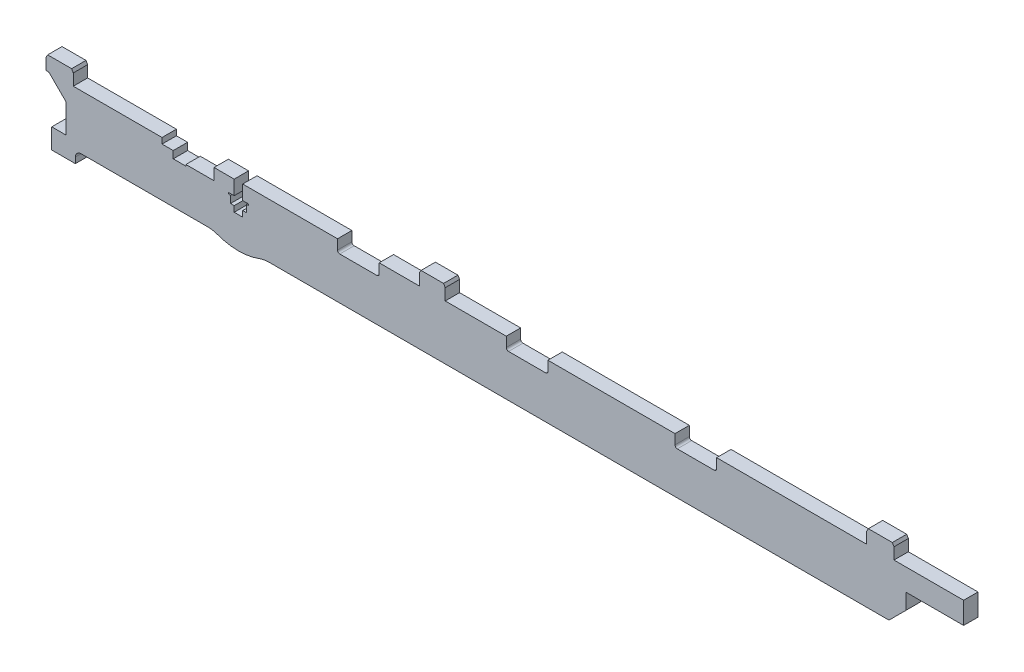
from build123d import *

# Parameters (mm, degrees)
BOSS_EXTRUDE1_DEPTH   = 5
CHAMFER1_SIZE         = 6
CUT_EXTRUDE2_DEPTH    = 6
CHAMFER3_SIZE         = 1
CHAMFER3_SIZE2        = 0.577350269
CHAMFER3_PART_2_SIZE  = 1
CHAMFER3_PART_2_SIZE2 = 0.577350269
CHAMFER3_PART_3_SIZE  = 1
CHAMFER3_PART_3_SIZE2 = 0.577350269
CHAMFER4_SIZE         = 1
CHAMFER4_SIZE2        = 0.577350269
CHAMFER4_PART_2_SIZE  = 1
CHAMFER4_PART_2_SIZE2 = 0.577350269
CHAMFER4_PART_3_SIZE  = 1
CHAMFER4_PART_3_SIZE2 = 0.577350269
FILLET1_R             = 0.8


with BuildPart() as part:
    # Sketch1 → Boss-Extrude1 (new body)
    with BuildSketch(Plane.XY):
        with BuildLine():
            Line((-250.8, 3.6), (-241, 3.6))
            Line((-241, 3.6), (-241, 7.6))
            Line((-241, 7.6), (-233.98, 7.6))
            Line((-233.98, 7.6), (-233.98, 2.6))
            Line((-233.98, 2.6), (-236, 2.6))
            Line((-236, 2.6), (-236, 2.1))
            Line((-236, 2.1), (-235.25, 2.1))
            Line((-235.25, 2.1), (-235.25, -0.4))
            Line((-235.25, -0.4), (-233.98, -0.4))
            Line((-233.98, -0.4), (-233.98, -2.4))
            Line((-233.98, -2.4), (-231.02, -2.4))
            Line((-231.02, -2.4), (-231.02, -0.4))
            Line((-231.02, -0.4), (-229.75, -0.4))
            Line((-229.75, -0.4), (-229.75, 2.1))
            Line((-229.75, 2.1), (-229, 2.1))
            Line((-229, 2.1), (-229, 2.6))
            Line((-229, 2.6), (-231.02, 2.6))
            Line((-231.02, 2.6), (-231.02, 7.6))
            Line((-231.02, 7.6), (-198, 7.6))
            Line((-198, 7.6), (-198, 3.4))
            Line((-198, 3.4), (-183.5, 3.4))
            Line((-183.5, 3.4), (-183.5, 7.6))
            Line((-183.5, 7.6), (-169.5, 7.6))
            Line((-169.5, 7.6), (-169.5, 12.6))
            Line((-169.5, 12.6), (-160.5, 12.6))
            Line((-160.5, 12.6), (-160.5, 7.6))
            Line((-160.5, 7.6), (-139.25, 7.6))
            Line((-139.25, 7.6), (-139.25, 3.4))
            Line((-139.25, 3.4), (-124.75, 3.4))
            Line((-124.75, 3.4), (-124.75, 7.6))
            Line((-124.75, 7.6), (-80.5, 7.6))
            Line((-80.5, 7.6), (-80.5, 3.4))
            Line((-80.5, 3.4), (-66, 3.4))
            Line((-66, 3.4), (-66, 7.6))
            Line((-66, 7.6), (-13.75, 7.6))
            Line((-13.75, 7.6), (-13.75, 12.6))
            Line((-13.75, 12.6), (-4.25, 12.6))
            Line((-4.25, 12.6), (-4.25, 7.6))
            Line((-4.25, 7.6), (20, 7.6))
            Line((20, 7.6), (20, 0))
            Line((20, 0), (0, 0))
            Line((0, 0), (0, -11.4))
            Line((0, -11.4), (-221.799463771, -11.4))
            ThreePointArc((-221.799463771, -11.4), (-223.557706142, -11.555784248), (-225.261167219, -12.018283247))
            ThreePointArc((-225.261167219, -12.018283247), (-232.5, -13.3111869), (-239.738832781, -12.018283247))
            ThreePointArc((-239.738832781, -12.018283247), (-241.442293858, -11.555784248), (-243.200536229, -11.4))
            Line((-243.200536229, -11.4), (-287.270831989, -11.4))
            ThreePointArc((-287.270831989, -11.4), (-289.270831989, -13.4), (-287.270831989, -15.4))
            Line((-287.270831989, -15.4), (-282, -15.4))
            Line((-282, -15.4), (-282, -18.281197846))
            Line((-282, -18.281197846), (-283, -20.013248654))
            Line((-283, -20.013248654), (-286, -18.281197846))
            Line((-286, -18.281197846), (-290, -20.590598923))
            Line((-290, -20.590598923), (-290, -25.209401077))
            Line((-290, -25.209401077), (-286, -27.518802154))
            Line((-286, -27.518802154), (-283, -25.786751346))
            Line((-283, -25.786751346), (-282, -27.518802154))
            Line((-282, -27.518802154), (-282, -30.9))
            Line((-282, -30.9), (-297.5, -30.9))
            Line((-297.5, -30.9), (-297.5, -8.4))
            Line((-297.5, -8.4), (-292.5, -8.4))
            Line((-292.5, -8.4), (-292.5, 1.6))
            Line((-292.5, 1.6), (-298.5, 7.6))
            Line((-298.5, 7.6), (-299.5, 7.6))
            Line((-299.5, 7.6), (-299.5, 12.6))
            Line((-299.5, 12.6), (-290, 12.6))
            Line((-290, 12.6), (-290, 7.6))
            Line((-290, 7.6), (-259.093151184, 7.6))
            Line((-259.093151184, 7.6), (-259.093151184, 5.6))
            Line((-259.093151184, 5.6), (-255.2, 5.6))
            Line((-255.2, 5.6), (-255.2, 3.1))
            Line((-255.2, 3.1), (-250.8, 3.1))
            Line((-250.8, 3.1), (-250.8, 3.6))
        make_face()
    extrude(amount=BOSS_EXTRUDE1_DEPTH)

    # Chamfer1
    chamfer1_edges = [part.edges().sort_by_distance(p)[0] for p in [
        (0, -11.4, 2.5),
    ]]
    chamfer(chamfer1_edges, length=CHAMFER1_SIZE)

    # Sketch3 → Cut-Extrude2 (cut, through all)
    with BuildSketch(Plane.XY.offset(5)):
        Polygon((-289.270831989, -13.4), (-289.270831989, -15.4), (-297.5, -15.4), (-297.5, -30.9), (-282, -30.9), (-282, -13.4), align=None)
    extrude(amount=-CUT_EXTRUDE2_DEPTH, mode=Mode.SUBTRACT)

    # Chamfer3
    chamfer3_edges = [part.edges().sort_by_distance(p)[0] for p in [
        (-290, 12.6, 2.5),
    ]]
    chamfer3_side = [part.faces().sort_by_distance(p)[0] for p in [
        (-290, 10.1, 2.5),
    ]]
    chamfer(chamfer3_edges, length=CHAMFER3_SIZE, length2=CHAMFER3_SIZE2, reference=chamfer3_side[0])

    # Chamfer3 part 2
    chamfer3_part_2_edges = [part.edges().sort_by_distance(p)[0] for p in [
        (-160.5, 12.6, 2.5),
    ]]
    chamfer3_part_2_side = [part.faces().sort_by_distance(p)[0] for p in [
        (-160.5, 10.1, 2.5),
    ]]
    chamfer(chamfer3_part_2_edges, length=CHAMFER3_PART_2_SIZE, length2=CHAMFER3_PART_2_SIZE2, reference=chamfer3_part_2_side[0])

    # Chamfer3 part 3
    chamfer3_part_3_edges = [part.edges().sort_by_distance(p)[0] for p in [
        (-4.25, 12.6, 2.5),
    ]]
    chamfer3_part_3_side = [part.faces().sort_by_distance(p)[0] for p in [
        (-4.25, 10.1, 2.5),
    ]]
    chamfer(chamfer3_part_3_edges, length=CHAMFER3_PART_3_SIZE, length2=CHAMFER3_PART_3_SIZE2, reference=chamfer3_part_3_side[0])

    # Chamfer4
    chamfer4_edges = [part.edges().sort_by_distance(p)[0] for p in [
        (-299.5, 12.6, 2.5),
    ]]
    chamfer4_side = [part.faces().sort_by_distance(p)[0] for p in [
        (-299.5, 10.1, 2.5),
    ]]
    chamfer(chamfer4_edges, length=CHAMFER4_SIZE, length2=CHAMFER4_SIZE2, reference=chamfer4_side[0])

    # Chamfer4 part 2
    chamfer4_part_2_edges = [part.edges().sort_by_distance(p)[0] for p in [
        (-169.5, 12.6, 2.5),
    ]]
    chamfer4_part_2_side = [part.faces().sort_by_distance(p)[0] for p in [
        (-169.5, 10.1, 2.5),
    ]]
    chamfer(chamfer4_part_2_edges, length=CHAMFER4_PART_2_SIZE, length2=CHAMFER4_PART_2_SIZE2, reference=chamfer4_part_2_side[0])

    # Chamfer4 part 3
    chamfer4_part_3_edges = [part.edges().sort_by_distance(p)[0] for p in [
        (-13.75, 12.6, 2.5),
    ]]
    chamfer4_part_3_side = [part.faces().sort_by_distance(p)[0] for p in [
        (-13.75, 10.1, 2.5),
    ]]
    chamfer(chamfer4_part_3_edges, length=CHAMFER4_PART_3_SIZE, length2=CHAMFER4_PART_3_SIZE2, reference=chamfer4_part_3_side[0])

    # Fillet1
    fillet1_edges = [part.edges().sort_by_distance(p)[0] for p in [
        (-198, 3.4, 2.5),
        (-183.5, 3.4, 2.5),
        (-139.25, 3.4, 2.5),
        (-124.75, 3.4, 2.5),
        (-80.5, 3.4, 2.5),
        (-66, 3.4, 2.5),
    ]]
    fillet(fillet1_edges, radius=FILLET1_R)


solid = part.part
